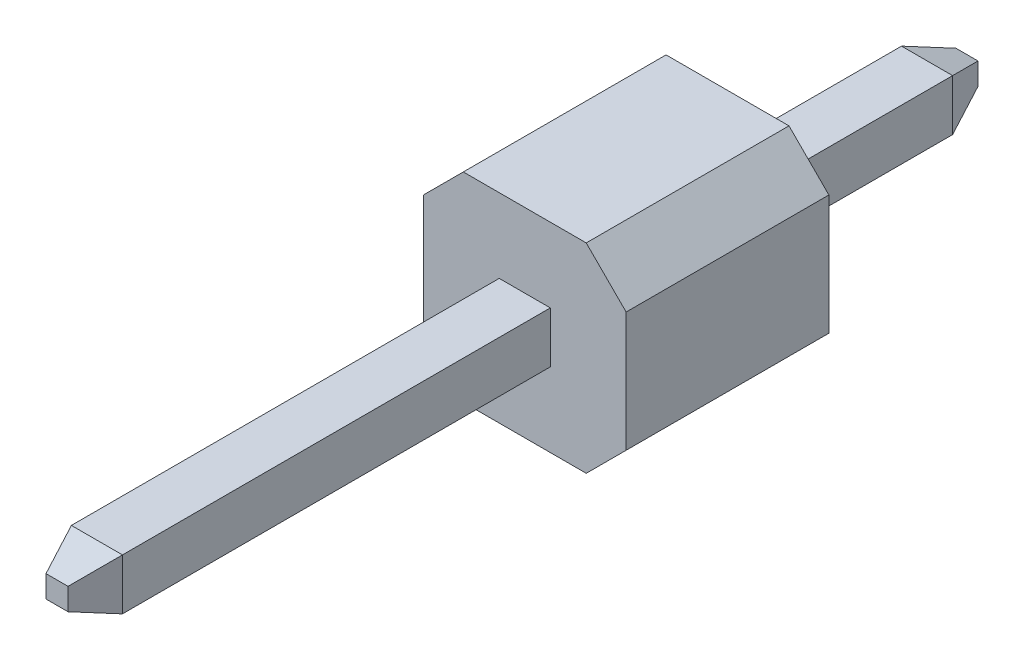
from build123d import *

# Parameters (mm, degrees)
SKETCH1_W             = 0.64
SKETCH1_H             = 0.64
BOSS_EXTRUDE1_DEPTH   = 8.4
SKETCH2_W             = 0.64
SKETCH2_H             = 0.64
BOSS_EXTRUDE2_DEPTH   = 3
CHAMFER1_SIZE         = 0.5
CHAMFER1_SIZE2        = 0.181985117
CHAMFER1_PART_2_SIZE  = 0.5
CHAMFER1_PART_2_SIZE2 = 0.181985117
CHAMFER1_PART_3_SIZE  = 0.5
CHAMFER1_PART_3_SIZE2 = 0.181985117
CHAMFER1_PART_4_SIZE  = 0.5
CHAMFER1_PART_4_SIZE2 = 0.181985117
SKETCH3_W             = 2.54
SKETCH3_H             = 2.5
BOSS_EXTRUDE3_DEPTH   = 2.54
CHAMFER2_SIZE         = 0.5


with BuildPart() as part:
    # Sketch1 → Boss-Extrude1 (new body)
    with BuildSketch(Plane.XY):
        Rectangle(SKETCH1_W, SKETCH1_H)
    extrude(amount=BOSS_EXTRUDE1_DEPTH)

    # Sketch2 → Boss-Extrude2 (add)
    with BuildSketch(Plane(origin=(0, 0, 0), x_dir=(-1, 0, 0), z_dir=(0, 0, -1))):
        Rectangle(SKETCH2_W, SKETCH2_H)
    extrude(amount=BOSS_EXTRUDE2_DEPTH)

    # Chamfer1
    chamfer1_edges = [part.edges().sort_by_distance(p)[0] for p in [
        (0.32, 0, 8.4),
        (0.32, 0, -3),
    ]]
    chamfer1_side = [part.faces().sort_by_distance(p)[0] for p in [
        (0.32, 0, 2.7),
    ]]
    chamfer(chamfer1_edges, length=CHAMFER1_SIZE, length2=CHAMFER1_SIZE2, reference=chamfer1_side[0])

    # Chamfer1 part 2
    chamfer1_part_2_edges = [part.edges().sort_by_distance(p)[0] for p in [
        (0, 0.32, 8.4),
        (0, 0.32, -3),
    ]]
    chamfer1_part_2_side = [part.faces().sort_by_distance(p)[0] for p in [
        (0, 0.32, 2.7),
    ]]
    chamfer(chamfer1_part_2_edges, length=CHAMFER1_PART_2_SIZE, length2=CHAMFER1_PART_2_SIZE2, reference=chamfer1_part_2_side[0])

    # Chamfer1 part 3
    chamfer1_part_3_edges = [part.edges().sort_by_distance(p)[0] for p in [
        (-0.32, 0, -3),
        (-0.32, 0, 8.4),
    ]]
    chamfer1_part_3_side = [part.faces().sort_by_distance(p)[0] for p in [
        (-0.32, 0, 2.7),
    ]]
    chamfer(chamfer1_part_3_edges, length=CHAMFER1_PART_3_SIZE, length2=CHAMFER1_PART_3_SIZE2, reference=chamfer1_part_3_side[0])

    # Chamfer1 part 4
    chamfer1_part_4_edges = [part.edges().sort_by_distance(p)[0] for p in [
        (0, -0.32, -3),
        (0, -0.32, 8.4),
    ]]
    chamfer1_part_4_side = [part.faces().sort_by_distance(p)[0] for p in [
        (0, -0.32, 2.7),
    ]]
    chamfer(chamfer1_part_4_edges, length=CHAMFER1_PART_4_SIZE, length2=CHAMFER1_PART_4_SIZE2, reference=chamfer1_part_4_side[0])

    # Sketch3 → Boss-Extrude3 (add)
    with BuildSketch(Plane.XY):
        Rectangle(SKETCH3_W, SKETCH3_H)
    extrude(amount=BOSS_EXTRUDE3_DEPTH)

    # Chamfer2
    chamfer2_edges = [part.edges().sort_by_distance(p)[0] for p in [
        (-1.27, 1.25, 1.27),
        (-1.27, -1.25, 1.27),
        (1.27, -1.25, 1.27),
        (1.27, 1.25, 1.27),
    ]]
    chamfer(chamfer2_edges, length=CHAMFER2_SIZE)


solid = part.part
